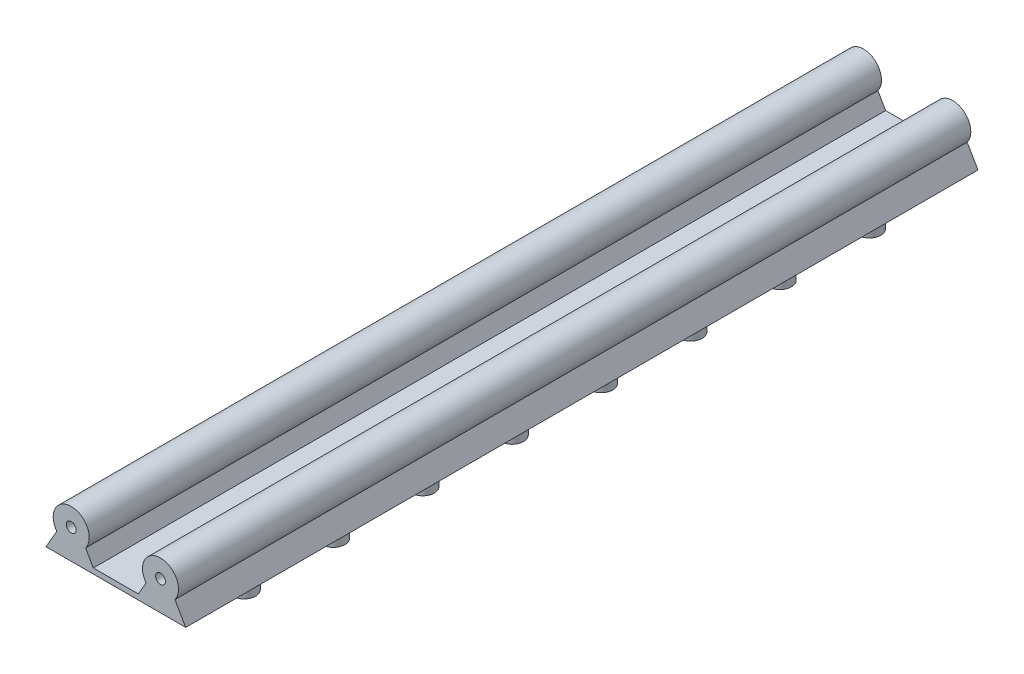
from build123d import *

# Parameters (mm, degrees)
SKETCH1_R           = 5
BOSS_EXTRUDE1_DEPTH = 220
SKETCH4_R           = 3.2
BOSS_EXTRUDE3_DEPTH = 6
BOSS_EXTRUDE4_DEPTH = 220
SKETCH5_R           = 1.37
CUT_EXTRUDE1_DEPTH  = 7
SKETCH6_R           = 1.37
CUT_EXTRUDE2_DEPTH  = 7


with BuildPart() as part:
    # Sketch1 → Boss-Extrude1 (new body)
    with BuildSketch(Plane.XY):
        Circle(SKETCH1_R)
        with BuildLine():
            Line((-4, -3), (-7, -8.196152423))
            Line((-7, -8.196152423), (7, -8.196152423))
            Line((7, -8.196152423), (4, -3))
            ThreePointArc((4, -3), (0, 5), (-4, -3))
        make_face()
        with BuildLine():
            Line((28.8, -3), (31.8, -8.196152423))
            Line((31.8, -8.196152423), (17.8, -8.196152423))
            Line((17.8, -8.196152423), (20.8, -3))
            ThreePointArc((20.8, -3), (24.8, 5), (28.8, -3))
        make_face()
    extrude(amount=BOSS_EXTRUDE1_DEPTH)

    # Sketch4 → Boss-Extrude3 (add)
    with BuildSketch(Plane.XZ.offset(8.196152423)):
        with Locations((0, 196.8)):
            Circle(SKETCH4_R)
        with Locations((24.8, 196.8)):
            Circle(SKETCH4_R)
        with Locations((24.8, 172)):
            Circle(SKETCH4_R)
        with Locations((24.8, 147.2)):
            Circle(SKETCH4_R)
        with Locations((24.8, 122.4)):
            Circle(SKETCH4_R)
        with Locations((24.8, 97.6)):
            Circle(SKETCH4_R)
        with Locations((24.8, 72.8)):
            Circle(SKETCH4_R)
        with Locations((24.8, 48)):
            Circle(SKETCH4_R)
        with Locations((24.8, 23.2)):
            Circle(SKETCH4_R)
        with Locations((0, 172)):
            Circle(SKETCH4_R)
        with Locations((0, 147.2)):
            Circle(SKETCH4_R)
        with Locations((0, 122.4)):
            Circle(SKETCH4_R)
        with Locations((0, 97.6)):
            Circle(SKETCH4_R)
        with Locations((0, 72.8)):
            Circle(SKETCH4_R)
        with Locations((0, 48)):
            Circle(SKETCH4_R)
        with Locations((0, 23.2)):
            Circle(SKETCH4_R)
    extrude(amount=BOSS_EXTRUDE3_DEPTH)

    # Sketch3 → Boss-Extrude4 (add)
    with BuildSketch(Plane.XY.offset(220)):
        Polygon((7, -8.196152423), (17.8, -8.196152423), (18.65, -8.196152423), (18.65, -6.723909236), (6.15, -6.723909236), (6.15, -8.196152423), align=None)
    extrude(amount=-BOSS_EXTRUDE4_DEPTH)

    # Sketch5 → Cut-Extrude1 (cut)
    with BuildSketch(Plane(origin=(0, 0, 0), x_dir=(-1, 0, 0), z_dir=(0, 0, -1))):
        Circle(SKETCH5_R)
        with Locations((-24.8, 0)):
            Circle(SKETCH5_R)
    extrude(amount=-CUT_EXTRUDE1_DEPTH, mode=Mode.SUBTRACT)

    # Sketch6 → Cut-Extrude2 (cut)
    with BuildSketch(Plane.XY.offset(220)):
        Circle(SKETCH6_R)
        with Locations((24.8, 0)):
            Circle(SKETCH6_R)
    extrude(amount=-CUT_EXTRUDE2_DEPTH, mode=Mode.SUBTRACT)


solid = part.part
